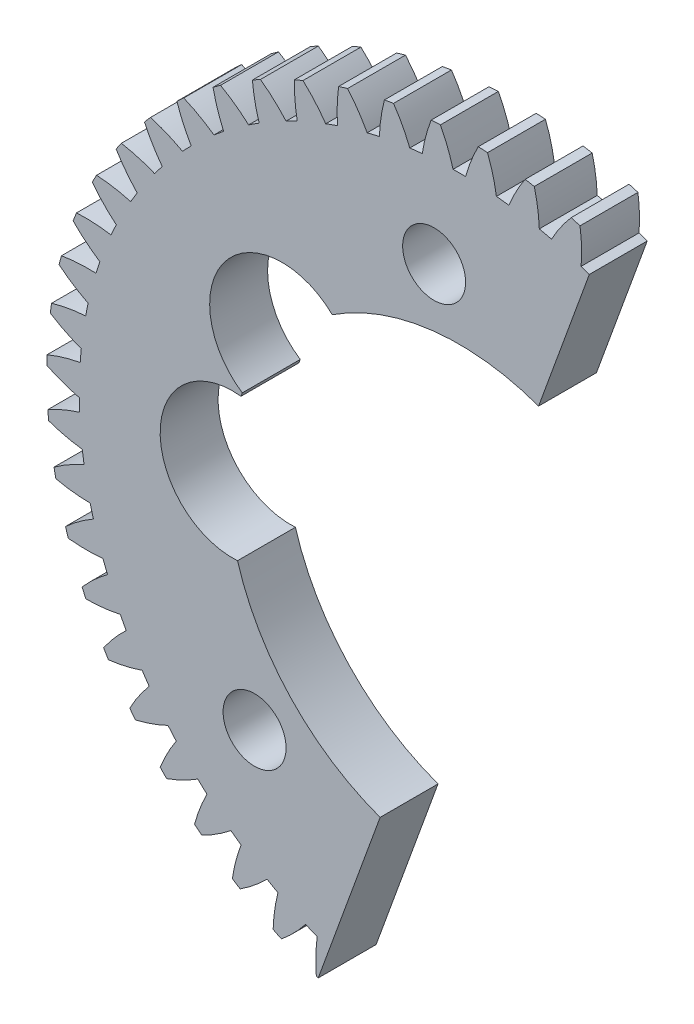
from build123d import *

# Parameters (mm, degrees)
MODEL_R             = 2.5
BOSS_EXTRUDE1_DEPTH = 4
SKETCH3_R           = 16
CUT_EXTRUDE1_DEPTH  = 4
SKETCH4_R           = 2.175
CUT_EXTRUDE4_DEPTH  = 4
CUT_EXTRUDE5_DEPTH  = 4
SKETCH7_R           = 5
CUT_EXTRUDE6_DEPTH  = 4
CIRPATTERN2_COUNT   = 2
CIRPATTERN2_ANGLE   = 130


with BuildPart() as part:
    # Model → Boss-Extrude1 (new body)
    with BuildSketch(Plane.XY):
        with BuildLine():
            ThreePointArc((-28.477434739, 1.133891841), (-28.488377496, 0.813847448), (-28.495723539, 0.493700304))
            ThreePointArc((-28.495723539, 0.493700304), (-27.393467785, 0.027569431), (-26.247097137, -0.316058386))
            ThreePointArc((-26.247097137, -0.316058386), (-26.23829547, -0.749567777), (-26.222334246, -1.182872637))
            ThreePointArc((-26.222334246, -1.182872637), (-27.34721798, -1.591384969), (-28.421065212, -2.119682102))
            ThreePointArc((-28.421065212, -2.119682102), (-28.39545433, -2.438887742), (-28.366258465, -2.757785467))
            ThreePointArc((-28.366258465, -2.757785467), (-27.21805259, -3.095230288), (-26.03998367, -3.305941842))
            ThreePointArc((-26.03998367, -3.305941842), (-25.981823028, -3.73562219), (-25.916572812, -4.164283211))
            ThreePointArc((-25.916572812, -4.164283211), (-26.987557359, -4.698359835), (-27.994183636, -5.345622747))
            ThreePointArc((-27.994183636, -5.345622747), (-27.932352991, -5.659828299), (-27.866995832, -5.973319287))
            ThreePointArc((-27.866995832, -5.973319287), (-26.687808456, -6.177678948), (-25.493399194, -6.25272729))
            ThreePointArc((-25.493399194, -6.25272729), (-25.386637789, -6.672977054), (-25.272949217, -7.091405986))
            ThreePointArc((-25.272949217, -7.091405986), (-26.276072656, -7.744084395), (-27.202355065, -8.501875025))
            ThreePointArc((-27.202355065, -8.501875025), (-27.105110714, -8.80698434), (-27.004444291, -9.110981755))
            ThreePointArc((-27.004444291, -9.110981755), (-25.809647924, -9.179592114), (-24.614469271, -9.117998876))
            ThreePointArc((-24.614469271, -9.117998876), (-24.460498903, -9.523339458), (-24.29985408, -9.926081438))
            ThreePointArc((-24.29985408, -9.926081438), (-25.222039162, -10.688852972), (-26.055902194, -11.54729236))
            ThreePointArc((-26.055902194, -11.54729236), (-25.924511868, -11.839327871), (-25.78984852, -12.129868643))
            ThreePointArc((-25.78984852, -12.129868643), (-24.595019161, -12.061835259), (-23.414652099, -11.864403402))
            ThreePointArc((-23.414652099, -11.864403402), (-23.215480006, -12.249550567), (-23.009973182, -12.631355239))
            ThreePointArc((-23.009973182, -12.631355239), (-23.839197815, -13.494276004), (-24.569770792, -14.442173079))
            ThreePointArc((-24.569770792, -14.442173079), (-24.405947362, -14.717327657), (-24.239042634, -14.990624143))
            ThreePointArc((-24.239042634, -14.990624143), (-23.05975671, -14.786833935), (-21.909589129, -14.456137285))
            ThreePointArc((-21.909589129, -14.456137285), (-21.667811823, -14.816070052), (-21.420122094, -15.171960007))
            ThreePointArc((-21.420122094, -15.171960007), (-22.145576068, -16.123780511), (-22.763334852, -17.148777986))
            ThreePointArc((-22.763334852, -17.148777986), (-22.569214009, -17.40346457), (-22.372243758, -17.655953932))
            ThreePointArc((-22.372243758, -17.655953932), (-21.223875065, -17.319063617), (-20.118901158, -16.859413312))
            ThreePointArc((-20.118901158, -16.859413312), (-19.837670577, -17.189439405), (-19.551026958, -17.514775074))
            ThreePointArc((-19.551026958, -17.514775074), (-20.163252869, -18.543086881), (-20.660144031, -19.631822346))
            ThreePointArc((-20.660144031, -19.631822346), (-20.438256436, -19.862720707), (-20.213788471, -20.09111136))
            ThreePointArc((-20.213788471, -20.09111136), (-19.111307751, -19.625512819), (-18.065932542, -19.042901102))
            ThreePointArc((-18.065932542, -19.042901102), (-17.748914957, -19.338718128), (-17.427054285, -19.629258263))
            ThreePointArc((-17.427054285, -19.629258263), (-17.918070833, -20.720655756), (-18.287616636, -21.858935879))
            ThreePointArc((-18.287616636, -21.858935879), (-18.040854934, -22.063035903), (-17.791815538, -22.264350426))
            ThreePointArc((-17.791815538, -22.264350426), (-16.749595313, -21.676113448), (-15.777446868, -20.978135554))
            ThreePointArc((-15.777446868, -20.978135554), (-15.428775087, -21.235887085), (-15.075893309, -21.487844051))
            ThreePointArc((-15.075893309, -21.487844051), (-15.439299342, -22.628099195), (-15.676682192, -23.801084754))
            ThreePointArc((-15.676682192, -23.801084754), (-15.408263298, -23.975725686), (-15.13789908, -24.147339635))
            ThreePointArc((-15.13789908, -24.147339635), (-14.169526285, -23.444132788), (-13.283278045, -22.639887928))
            ThreePointArc((-13.283278045, -22.639887928), (-12.907497539, -22.856213778), (-12.528195008, -23.06630293))
            ThreePointArc((-12.528195008, -23.06630293), (-12.759252972, -24.240550755), (-12.86137822, -25.43295009))
            ThreePointArc((-12.86137822, -25.43295009), (-12.574801385, -25.575855218), (-12.286636957, -25.715531343))
            ThreePointArc((-12.286636957, -25.715531343), (-11.404735812, -24.906522005), (-10.615941378, -24.006494739))
            ThreePointArc((-10.615941378, -24.006494739), (-10.217951021, -24.178574771), (-9.817172525, -24.344057275))
            ThreePointArc((-9.817172525, -24.344057275), (-9.912870228, -25.536989666), (-9.878406515, -26.733258027))
            ThreePointArc((-9.878406515, -26.733258027), (-9.577407707, -26.842564364), (-9.275199732, -26.948481774))
            ThreePointArc((-9.275199732, -26.948481774), (-8.491267167, -26.044216618), (-7.810209681, -25.060140178))
            ThreePointArc((-7.810209681, -25.060140178), (-7.395197884, -25.185731064), (-6.978168185, -25.304449604))
            ThreePointArc((-6.978168185, -25.304449604), (-6.93725806, -26.500514862), (-6.766654673, -27.685057062))
            ThreePointArc((-6.766654673, -27.685057062), (-6.455157872, -27.759339633), (-6.142846094, -27.830117532))
            ThreePointArc((-6.142846094, -27.830117532), (-5.467101869, -26.842385037), (-4.902659956, -25.787088365))
            ThreePointArc((-4.902659956, -25.787088365), (-4.476037034, -25.864552837), (-4.048192751, -25.934959735))
            ThreePointArc((-4.048192751, -25.934959735), (-3.871208124, -27.11856532), (-3.56668914, -28.27593904))
            ThreePointArc((-3.56668914, -28.27593904), (-3.248755182, -28.314229457), (-2.930411062, -28.348945148))
            ThreePointArc((-2.930411062, -28.348945148), (-2.371664537, -27.290621918), (-1.931196562, -26.177862419))
            ThreePointArc((-1.931196562, -26.177862419), (-1.498524196, -26.206190609), (-1.065442934, -26.227368003))
            ThreePointArc((-1.065442934, -26.227368003), (-0.75469107, -27.383083806), (-0.320226359, -28.498200909))
            ThreePointArc((-0.320226359, -28.498200909), (0, -28.5), (0.320226359, -28.49820091))
            ThreePointArc((0.320226359, -28.49820091), (0.75469107, -27.383083806), (1.065442934, -26.227368003))
            ThreePointArc((1.065442934, -26.227368003), (1.498524196, -26.206190609), (1.931196562, -26.177862419))
            ThreePointArc((1.931196562, -26.177862419), (2.371664537, -27.290621918), (2.930411062, -28.348945148))
            ThreePointArc((2.930411062, -28.348945148), (3.248755182, -28.314229457), (3.56668914, -28.27593904))
            ThreePointArc((3.56668914, -28.27593904), (3.871208124, -27.11856532), (4.048192751, -25.934959735))
            ThreePointArc((4.048192751, -25.934959735), (4.476037034, -25.864552837), (4.902659956, -25.787088365))
            ThreePointArc((4.902659956, -25.787088365), (5.467101869, -26.842385037), (6.142846094, -27.830117532))
            ThreePointArc((6.142846094, -27.830117532), (6.455157872, -27.759339633), (6.766654673, -27.685057062))
            ThreePointArc((6.766654673, -27.685057062), (6.93725806, -26.500514862), (6.978168185, -25.304449604))
            ThreePointArc((6.978168185, -25.304449604), (7.395197884, -25.185731064), (7.810209681, -25.060140178))
            ThreePointArc((7.810209681, -25.060140178), (8.491267167, -26.044216618), (9.275199732, -26.948481774))
            ThreePointArc((9.275199732, -26.948481774), (9.577407707, -26.842564364), (9.878406515, -26.733258027))
            ThreePointArc((9.878406515, -26.733258027), (9.912870228, -25.536989666), (9.817172525, -24.344057275))
            ThreePointArc((9.817172525, -24.344057275), (10.217951021, -24.178574771), (10.615941378, -24.006494739))
            ThreePointArc((10.615941378, -24.006494739), (11.404735812, -24.906522005), (12.286636957, -25.715531343))
            ThreePointArc((12.286636957, -25.715531343), (12.574801385, -25.575855218), (12.86137822, -25.43295009))
            ThreePointArc((12.86137822, -25.43295009), (12.759252972, -24.240550755), (12.528195008, -23.06630293))
            ThreePointArc((12.528195008, -23.06630293), (12.907497539, -22.856213778), (13.283278045, -22.639887928))
            ThreePointArc((13.283278045, -22.639887928), (14.169526285, -23.444132788), (15.13789908, -24.147339635))
            ThreePointArc((15.13789908, -24.147339635), (15.408263297, -23.975725686), (15.676682191, -23.801084754))
            ThreePointArc((15.676682191, -23.801084754), (15.439299342, -22.628099195), (15.075893309, -21.487844051))
            ThreePointArc((15.075893309, -21.487844051), (15.428775087, -21.235887085), (15.777446868, -20.978135554))
            ThreePointArc((15.777446868, -20.978135554), (16.749595313, -21.676113448), (17.791815538, -22.264350426))
            ThreePointArc((17.791815538, -22.264350426), (18.040854934, -22.063035903), (18.287616636, -21.858935879))
            ThreePointArc((18.287616636, -21.858935879), (17.918070833, -20.720655756), (17.427054285, -19.629258263))
            ThreePointArc((17.427054285, -19.629258263), (17.748914957, -19.338718128), (18.065932542, -19.042901102))
            ThreePointArc((18.065932542, -19.042901102), (19.111307751, -19.625512819), (20.213788471, -20.09111136))
            ThreePointArc((20.213788471, -20.09111136), (20.438256436, -19.862720707), (20.660144031, -19.631822346))
            ThreePointArc((20.660144031, -19.631822346), (20.163252869, -18.543086881), (19.551026958, -17.514775074))
            ThreePointArc((19.551026958, -17.514775074), (19.837670577, -17.189439405), (20.118901158, -16.859413312))
            ThreePointArc((20.118901158, -16.859413312), (21.223875065, -17.319063617), (22.372243758, -17.655953932))
            ThreePointArc((22.372243758, -17.655953932), (22.569214009, -17.40346457), (22.763334852, -17.148777986))
            ThreePointArc((22.763334852, -17.148777986), (22.145576068, -16.123780511), (21.420122094, -15.171960007))
            ThreePointArc((21.420122094, -15.171960007), (21.667811823, -14.816070052), (21.909589129, -14.456137285))
            ThreePointArc((21.909589129, -14.456137285), (23.05975671, -14.786833935), (24.239042634, -14.990624143))
            ThreePointArc((24.239042634, -14.990624143), (24.405947362, -14.717327657), (24.569770792, -14.442173079))
            ThreePointArc((24.569770792, -14.442173079), (23.839197815, -13.494276004), (23.009973182, -12.631355239))
            ThreePointArc((23.009973182, -12.631355239), (23.215480006, -12.249550567), (23.414652099, -11.864403402))
            ThreePointArc((23.414652099, -11.864403402), (24.595019161, -12.061835259), (25.78984852, -12.129868643))
            ThreePointArc((25.78984852, -12.129868643), (25.924511868, -11.839327871), (26.055902194, -11.54729236))
            ThreePointArc((26.055902194, -11.54729236), (25.222039162, -10.688852972), (24.29985408, -9.926081438))
            ThreePointArc((24.29985408, -9.926081438), (24.460498903, -9.523339458), (24.614469271, -9.117998876))
            ThreePointArc((24.614469271, -9.117998876), (25.809647924, -9.179592114), (27.004444291, -9.110981756))
            ThreePointArc((27.004444291, -9.110981756), (27.105110714, -8.80698434), (27.202355065, -8.501875025))
            ThreePointArc((27.202355065, -8.501875025), (26.276072656, -7.744084395), (25.272949217, -7.091405986))
            ThreePointArc((25.272949217, -7.091405986), (25.386637789, -6.672977054), (25.493399194, -6.25272729))
            ThreePointArc((25.493399194, -6.25272729), (26.687808456, -6.177678948), (27.866995832, -5.973319287))
            ThreePointArc((27.866995832, -5.973319287), (27.932352991, -5.659828299), (27.994183636, -5.345622747))
            ThreePointArc((27.994183636, -5.345622747), (26.987557359, -4.698359835), (25.916572812, -4.164283211))
            ThreePointArc((25.916572812, -4.164283211), (25.981823028, -3.73562219), (26.03998367, -3.305941842))
            ThreePointArc((26.03998367, -3.305941842), (27.21805259, -3.095230288), (28.366258465, -2.757785467))
            ThreePointArc((28.366258465, -2.757785467), (28.39545433, -2.438887742), (28.421065212, -2.119682102))
            ThreePointArc((28.421065212, -2.119682102), (27.34721798, -1.591384969), (26.222334246, -1.182872637))
            ThreePointArc((26.222334246, -1.182872637), (26.23829547, -0.749567777), (26.247097137, -0.316058386))
            ThreePointArc((26.247097137, -0.316058386), (27.393467785, 0.027569431), (28.495723539, 0.493700304))
            ThreePointArc((28.495723539, 0.493700304), (28.488377496, 0.813847448), (28.477434739, 1.133891841))
            ThreePointArc((28.477434739, 1.133891841), (27.350365792, 1.536336033), (26.186247451, 1.813958491))
            ThreePointArc((26.186247451, 1.813958491), (26.152711603, 2.246258398), (26.112039552, 2.677945375))
            ThreePointArc((26.112039552, 2.677945375), (27.211767234, 3.150009741), (28.253703278, 3.738749937))
            ThreePointArc((28.253703278, 3.738749937), (28.209911094, 4.055972891), (28.162557353, 4.37268377))
            ThreePointArc((28.162557353, 4.37268377), (26.996959759, 4.644028546), (25.808782875, 4.787141897))
            ThreePointArc((25.808782875, 4.787141897), (25.726187146, 5.212801159), (25.636571599, 5.637038022))
            ThreePointArc((25.636571599, 5.637038022), (26.675319682, 6.231384856), (27.643352786, 6.935059247))
            ThreePointArc((27.643352786, 6.935059247), (27.563685359, 7.245222525), (27.480537963, 7.554471079))
            ThreePointArc((27.480537963, 7.554471079), (26.291607069, 7.691179044), (25.094861343, 7.697917586))
            ThreePointArc((25.094861343, 7.697917586), (24.964282496, 8.111387085), (24.826891729, 8.522643257))
            ThreePointArc((24.826891729, 8.522643257), (25.791118543, 9.23152434), (26.672628915, 10.040959454))
            ThreePointArc((26.672628915, 10.040959454), (26.558124833, 10.340019602), (26.440267734, 10.637774304))
            ThreePointArc((26.440267734, 10.637774304), (25.243503073, 10.638063262), (24.053789917, 10.508339148))
            ThreePointArc((24.053789917, 10.508339148), (23.876930246, 10.904228676), (23.693555357, 11.297142804))
            ThreePointArc((23.693555357, 11.297142804), (24.570690732, 12.111316787), (25.354186536, 13.015960398))
            ThreePointArc((25.354186536, 13.015960398), (25.206338533, 13.300018712), (25.055308181, 13.582397872))
            ThreePointArc((25.055308181, 13.582397872), (23.866311409, 13.446264056), (22.699140553, 13.181768438))
            ThreePointArc((22.699140553, 13.181768438), (22.478305695, 13.554916971), (22.251337257, 13.924366818))
            ThreePointArc((22.251337257, 13.924366818), (23.029946391, 14.833219697), (23.705213562, 15.821278393))
            ThreePointArc((23.705213562, 15.821278393), (23.525949063, 16.086631738), (23.343714368, 16.349954113))
            ThreePointArc((23.343714368, 16.349954113), (22.177985878, 16.079172235), (21.048573179, 15.683353218))
            ThreePointArc((21.048573179, 15.683353218), (20.786642053, 16.028896193), (20.519038946, 16.370065416))
            ThreePointArc((20.519038946, 16.370065416), (21.188971479, 17.361748904), (21.747206876, 18.420341829))
            ThreePointArc((21.747206876, 18.420341829), (21.538862869, 18.663530917), (21.327799539, 18.904363698))
            ThreePointArc((21.327799539, 18.904363698), (20.200536383, 18.502463814), (19.123605463, 17.980481504))
            ThreePointArc((19.123605463, 17.980481504), (18.823992743, 18.29391424), (18.519243583, 18.602355176))
            ThreePointArc((18.519243583, 18.602355176), (19.071765919, 19.663941163), (19.50569209, 20.779267939))
            ThreePointArc((19.50569209, 20.779267939), (19.270984658, 20.997122429), (19.033844226, 21.212325992))
            ThreePointArc((19.033844226, 21.212325992), (17.959742004, 20.684547481), (16.949332304, 20.043206715))
            ThreePointArc((16.949332304, 20.043206715), (16.6159439, 20.320443138), (16.278021558, 20.592134788))
            ThreePointArc((16.278021558, 20.592134788), (16.705930724, 21.709783877), (17.009890778, 22.867304514))
            ThreePointArc((17.009890778, 22.867304514), (16.75187969, 23.05698434), (16.491753645, 23.243753176))
            ThreePointArc((16.491753645, 23.243753176), (15.484814923, 22.596976438), (14.554098679, 21.844638076))
            ThreePointArc((14.554098679, 21.844638076), (14.191280817, 22.082063983), (13.824590629, 22.313464432))
            ThreePointArc((13.824590629, 22.313464432), (14.122308174, 23.472606357), (14.292339526, 24.657230803))
            ThreePointArc((14.292339526, 24.657230803), (14.014388352, 24.816263198), (13.734667835, 24.972162491))
            ThreePointArc((13.734667835, 24.972162491), (12.808019598, 24.21481925), (11.969130119, 23.361291171))
            ThreePointArc((11.969130119, 23.361291171), (11.581612687, 23.555811355), (11.190935018, 23.743903942))
            ThreePointArc((11.190935018, 23.743903942), (11.354579739, 24.929427516), (11.388465771, 26.12571238))
            ThreePointArc((11.388465771, 26.12571238), (11.09419803, 26.252024114), (10.798529624, 26.375021478))
            ThreePointArc((10.798529624, 26.375021478), (9.96425215, 25.516984862), (9.228125644, 24.57339411))
            ThreePointArc((9.228125644, 24.57339411), (8.820960523, 24.722472701), (8.411388455, 24.864805353))
            ThreePointArc((8.411388455, 24.864805353), (8.438826993, 26.061255463), (8.336125949, 27.253605342))
            ThreePointArc((8.336125949, 27.253605342), (8.02937787, 27.345549748), (7.721616066, 27.434041724))
            ThreePointArc((7.721616066, 27.434041724), (6.990585436, 26.486497552), (6.366818438, 25.465145277))
            ThreePointArc((6.366818438, 25.465145277), (5.945313648, 25.566838808), (5.522186581, 25.661556001))
            ThreePointArc((5.522186581, 25.661556001), (5.413061232, 26.85333509), (5.175111976, 28.02620588))
            ThreePointArc((5.175111976, 28.02620588), (4.85988249, 28.082584322), (4.544039434, 28.135417282))
            ThreePointArc((4.544039434, 28.135417282), (3.925785751, 27.110718242), (3.422510017, 26.024919331))
            ThreePointArc((3.422510017, 26.024919331), (2.992160518, 26.077902071), (2.560994558, 26.123769021))
            ThreePointArc((2.560994558, 26.123769021), (2.316727939, 27.295340426), (1.946632505, 28.433441963))
            ThreePointArc((1.946632505, 28.433441963), (1.62703111, 28.453519462), (1.307224299, 28.470004648))
            ThreePointArc((1.307224299, 28.470004648), (0.809807445, 27.381509258), (0.433583944, 26.245418761))
            ThreePointArc((0.433583944, 26.245418761), (0, 26.249), (-0.433583944, 26.245418761))
            ThreePointArc((-0.433583944, 26.245418761), (-0.809807445, 27.381509258), (-1.307224299, 28.470004648))
            ThreePointArc((-1.307224299, 28.470004648), (-1.62703111, 28.453519462), (-1.946632505, 28.433441964))
            ThreePointArc((-1.946632505, 28.433441964), (-2.316727939, 27.295340426), (-2.560994558, 26.123769021))
            ThreePointArc((-2.560994558, 26.123769021), (-2.992160518, 26.077902071), (-3.422510017, 26.024919331))
            ThreePointArc((-3.422510017, 26.024919331), (-3.925785751, 27.110718242), (-4.544039434, 28.135417282))
            ThreePointArc((-4.544039434, 28.135417282), (-4.85988249, 28.082584322), (-5.175111976, 28.02620588))
            ThreePointArc((-5.175111976, 28.02620588), (-5.413061232, 26.85333509), (-5.522186581, 25.661556001))
            ThreePointArc((-5.522186581, 25.661556001), (-5.945313648, 25.566838808), (-6.366818438, 25.465145277))
            ThreePointArc((-6.366818438, 25.465145277), (-6.990585436, 26.486497552), (-7.721616066, 27.434041724))
            ThreePointArc((-7.721616066, 27.434041724), (-8.02937787, 27.345549748), (-8.336125949, 27.253605342))
            ThreePointArc((-8.336125949, 27.253605342), (-8.438826993, 26.061255463), (-8.411388455, 24.864805353))
            ThreePointArc((-8.411388455, 24.864805353), (-8.820960522, 24.722472701), (-9.228125643, 24.573394111))
            ThreePointArc((-9.228125643, 24.573394111), (-9.96425215, 25.516984862), (-10.798529624, 26.375021478))
            ThreePointArc((-10.798529624, 26.375021478), (-11.09419803, 26.252024114), (-11.388465771, 26.12571238))
            ThreePointArc((-11.388465771, 26.12571238), (-11.354579739, 24.929427516), (-11.190935018, 23.743903942))
            ThreePointArc((-11.190935018, 23.743903942), (-11.581612687, 23.555811355), (-11.969130119, 23.361291171))
            ThreePointArc((-11.969130119, 23.361291171), (-12.808019598, 24.21481925), (-13.734667835, 24.972162491))
            ThreePointArc((-13.734667835, 24.972162491), (-14.014388352, 24.816263198), (-14.292339526, 24.657230803))
            ThreePointArc((-14.292339526, 24.657230803), (-14.122308174, 23.472606357), (-13.824590629, 22.313464432))
            ThreePointArc((-13.824590629, 22.313464432), (-14.191280817, 22.082063983), (-14.554098678, 21.844638076))
            ThreePointArc((-14.554098678, 21.844638076), (-15.484814923, 22.596976438), (-16.491753645, 23.243753176))
            ThreePointArc((-16.491753645, 23.243753176), (-16.75187969, 23.05698434), (-17.009890778, 22.867304514))
            ThreePointArc((-17.009890778, 22.867304514), (-16.705930724, 21.709783877), (-16.278021558, 20.592134788))
            ThreePointArc((-16.278021558, 20.592134788), (-16.6159439, 20.320443138), (-16.949332304, 20.043206715))
            ThreePointArc((-16.949332304, 20.043206715), (-17.959742004, 20.684547481), (-19.033844226, 21.212325992))
            ThreePointArc((-19.033844226, 21.212325992), (-19.270984658, 20.99712243), (-19.50569209, 20.779267939))
            ThreePointArc((-19.50569209, 20.779267939), (-19.071765919, 19.663941163), (-18.519243583, 18.602355176))
            ThreePointArc((-18.519243583, 18.602355176), (-18.823992743, 18.29391424), (-19.123605463, 17.980481503))
            ThreePointArc((-19.123605463, 17.980481503), (-20.200536383, 18.502463814), (-21.327799539, 18.904363698))
            ThreePointArc((-21.327799539, 18.904363698), (-21.538862869, 18.663530917), (-21.747206876, 18.420341829))
            ThreePointArc((-21.747206876, 18.420341829), (-21.188971479, 17.361748904), (-20.519038946, 16.370065416))
            ThreePointArc((-20.519038946, 16.370065416), (-20.786642053, 16.028896193), (-21.048573178, 15.683353218))
            ThreePointArc((-21.048573178, 15.683353218), (-22.177985878, 16.079172235), (-23.343714368, 16.349954113))
            ThreePointArc((-23.343714368, 16.349954113), (-23.525949063, 16.086631738), (-23.705213562, 15.821278393))
            ThreePointArc((-23.705213562, 15.821278393), (-23.029946391, 14.833219697), (-22.251337257, 13.924366818))
            ThreePointArc((-22.251337257, 13.924366818), (-22.478305695, 13.554916971), (-22.699140553, 13.181768438))
            ThreePointArc((-22.699140553, 13.181768438), (-23.866311409, 13.446264056), (-25.055308181, 13.582397872))
            ThreePointArc((-25.055308181, 13.582397872), (-25.206338533, 13.300018712), (-25.354186536, 13.015960398))
            ThreePointArc((-25.354186536, 13.015960398), (-24.570690732, 12.111316787), (-23.693555357, 11.297142804))
            ThreePointArc((-23.693555357, 11.297142804), (-23.876930246, 10.904228676), (-24.053789917, 10.508339148))
            ThreePointArc((-24.053789917, 10.508339148), (-25.243503073, 10.638063262), (-26.440267734, 10.637774304))
            ThreePointArc((-26.440267734, 10.637774304), (-26.558124833, 10.340019602), (-26.672628915, 10.040959453))
            ThreePointArc((-26.672628915, 10.040959453), (-25.791118543, 9.23152434), (-24.826891729, 8.522643257))
            ThreePointArc((-24.826891729, 8.522643257), (-24.964282496, 8.111387085), (-25.094861343, 7.697917586))
            ThreePointArc((-25.094861343, 7.697917586), (-26.291607069, 7.691179044), (-27.480537963, 7.554471079))
            ThreePointArc((-27.480537963, 7.554471079), (-27.563685359, 7.245222524), (-27.643352786, 6.935059247))
            ThreePointArc((-27.643352786, 6.935059247), (-26.675319682, 6.231384856), (-25.636571599, 5.637038022))
            ThreePointArc((-25.636571599, 5.637038022), (-25.726187146, 5.212801159), (-25.808782875, 4.787141897))
            ThreePointArc((-25.808782875, 4.787141897), (-26.996959759, 4.644028546), (-28.162557353, 4.37268377))
            ThreePointArc((-28.162557353, 4.37268377), (-28.209911094, 4.055972891), (-28.253703278, 3.738749937))
            ThreePointArc((-28.253703278, 3.738749937), (-27.211767234, 3.150009741), (-26.112039552, 2.677945375))
            ThreePointArc((-26.112039552, 2.677945375), (-26.152711603, 2.246258398), (-26.186247452, 1.813958491))
            ThreePointArc((-26.186247452, 1.813958491), (-27.350365792, 1.536336033), (-28.477434739, 1.133891841))
        make_face()
        Circle(MODEL_R, mode=Mode.SUBTRACT)
    extrude(amount=BOSS_EXTRUDE1_DEPTH)

    # Sketch3 → Cut-Extrude1 (cut)
    with BuildSketch(Plane.XY.offset(4)):
        Circle(SKETCH3_R)
    extrude(amount=-CUT_EXTRUDE1_DEPTH, mode=Mode.SUBTRACT)

    # Sketch4 → Cut-Extrude4 (cut)
    with BuildSketch(Plane.XY.offset(4)):
        with Locations((-14.142135624, -14.142135624)):
            Circle(SKETCH4_R)
    cut_extrude4 = extrude(amount=-CUT_EXTRUDE4_DEPTH, mode=Mode.SUBTRACT)

    # Sketch6 → Cut-Extrude5 (cut)
    with BuildSketch(Plane.XY.offset(4)):
        Polygon((13.541914667, 37.206104763), (0, 0), (41.55012172, -15.123007536), align=None)
        Polygon((41.55012172, -15.123007536), (0, 0), (-13.541914667, -37.206104763), align=None)
    extrude(amount=-CUT_EXTRUDE5_DEPTH, mode=Mode.SUBTRACT)

    # Sketch7 → Cut-Extrude6 (cut)
    with BuildSketch(Plane.XY.offset(4)):
        with Locations((-12.244334702, 9.777462232)):
            Circle(SKETCH7_R)
        with Locations((-15.664536135, 0.380536024)):
            Circle(SKETCH7_R)
    extrude(amount=-CUT_EXTRUDE6_DEPTH, mode=Mode.SUBTRACT)

    # CirPattern2: Cut-Extrude4 ×2 about axis
    cirpattern2_axis = Axis((0, 0, 4), (0, 0, -1))
    for i in range(1, CIRPATTERN2_COUNT):
        add(cut_extrude4.rotate(cirpattern2_axis, i * CIRPATTERN2_ANGLE / (CIRPATTERN2_COUNT - 1)), mode=Mode.SUBTRACT)


solid = part.part
